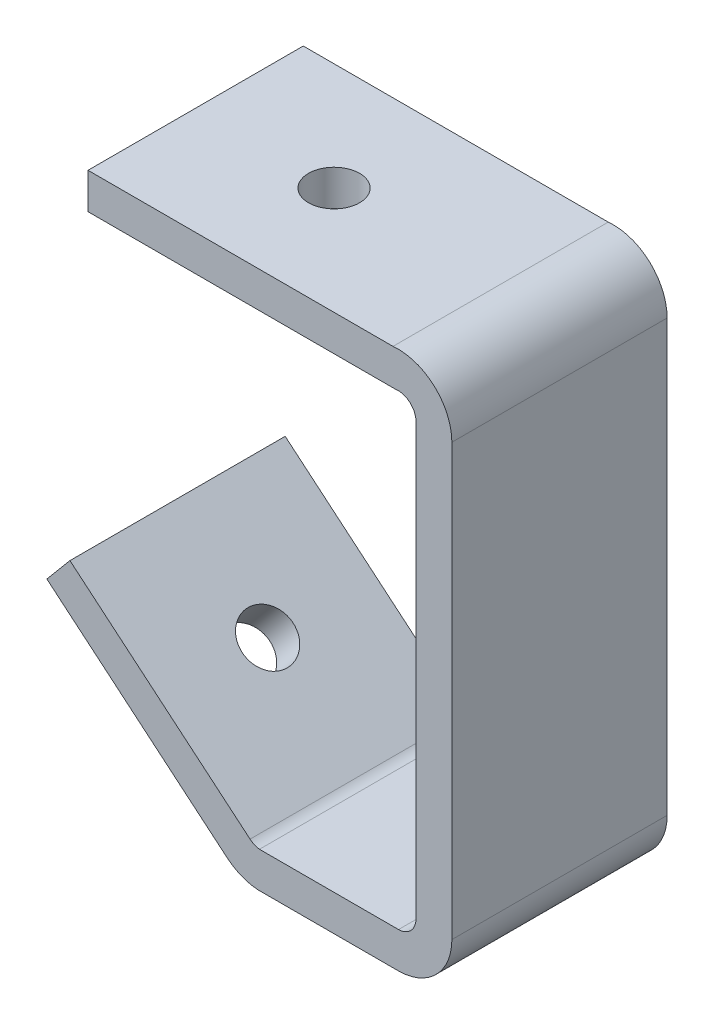
from build123d import *

# Parameters (mm, degrees)
BOSS_EXTRUDE1_DEPTH = 38.1
SKETCH2_R           = 4.52
CUT_EXTRUDE1_DEPTH  = 38.1
SKETCH3_R           = 4.515
CUT_EXTRUDE2_DEPTH  = 10


with BuildPart() as part:
    # Sketch1 → Boss-Extrude1 (new body)
    with BuildSketch(Plane.XY):
        with BuildLine():
            Line((0, 0), (53.98, 0))
            ThreePointArc((53.98, 0), (61.287211447, -2.441393787), (64.401363743, -9.488222735))
            Line((64.401363743, -9.488222735), (64.401363743, -85.721240556))
            ThreePointArc((64.401363743, -85.721240556), (61.664237719, -92.40538322), (55.025128035, -95.25))
            Line((55.025128035, -95.25), (30.071323434, -95.25))
            ThreePointArc((30.071323434, -95.25), (27.161692752, -94.580250085), (24.602099349, -93.043045718))
            Line((24.602099349, -93.043045718), (-7.280670374, -66.290225402))
            Line((-7.280670374, -66.290225402), (-3.198969052, -61.425843189))
            Line((-3.198969052, -61.425843189), (28.68380067, -88.178663504))
            ThreePointArc((28.68380067, -88.178663504), (29.463882201, -88.660646082), (30.349062467, -88.9))
            Line((30.349062467, -88.9), (54.96018039, -88.9))
            ThreePointArc((54.96018039, -88.9), (57.151148485, -87.938216318), (58.051363743, -85.721240556))
            Line((58.051363743, -85.721240556), (58.051363743, -9.488222735))
            ThreePointArc((58.051363743, -9.488222735), (56.930321756, -7.064776449), (54.357595252, -6.35))
            Line((54.357595252, -6.35), (0, -6.35))
            Line((0, -6.35), (0, 0))
        make_face()
    extrude(amount=BOSS_EXTRUDE1_DEPTH)

    # Sketch2 → Cut-Extrude1 (cut)
    with BuildSketch(Plane(origin=(0, 0, 0), x_dir=(1, 0, 0), z_dir=(0, 1, 0))):
        with Locations((24.5, -19.05)):
            Circle(SKETCH2_R)
    extrude(amount=-CUT_EXTRUDE1_DEPTH, mode=Mode.SUBTRACT)

    # Sketch3 → Cut-Extrude2 (cut)
    with BuildSketch(Plane(origin=(-35.649761578, -42.485731436, 0), x_dir=(0.766044443, -0.64278761, 0), z_dir=(-0.64278761, -0.766044443, 0))):
        with Locations((57.84321845, 19.05)):
            Circle(SKETCH3_R)
    extrude(amount=-CUT_EXTRUDE2_DEPTH, mode=Mode.SUBTRACT)


solid = part.part
